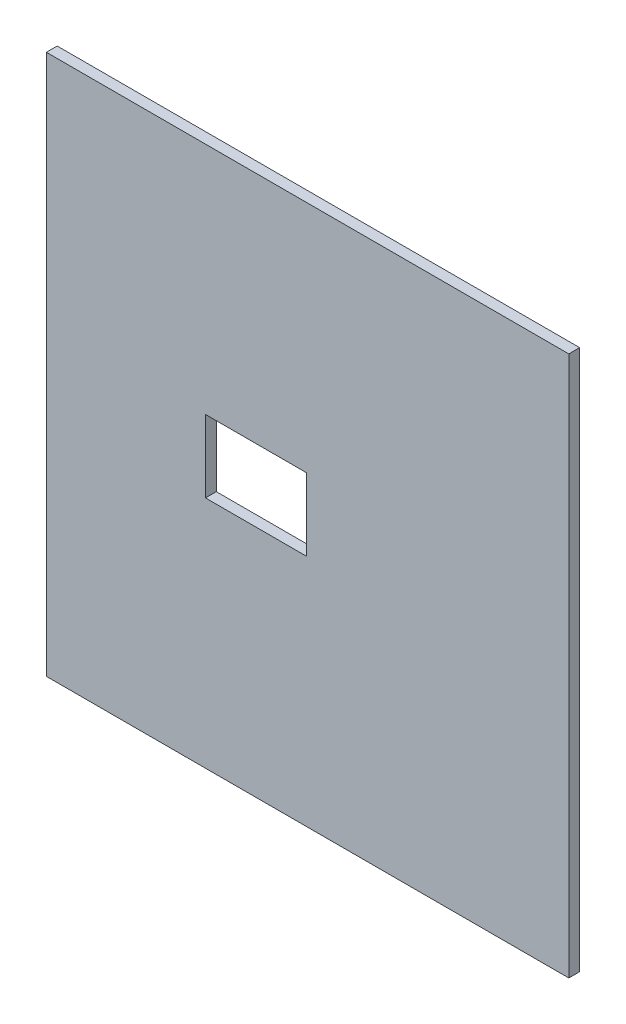
from build123d import *

# Parameters (mm, degrees)
SKETCH1_W           = 144.5
SKETCH1_H           = 149.5
BOSS_EXTRUDE1_DEPTH = 3
CUT_EXTRUDE1_REACH  = 5
SKETCH2_W           = 28
SKETCH2_H           = 20


with BuildPart() as part:
    # Sketch1 → Boss-Extrude1 (new body)
    with BuildSketch(Plane.XY):
        Rectangle(SKETCH1_W, SKETCH1_H)
    extrude(amount=BOSS_EXTRUDE1_DEPTH)

    # Sketch2 → Cut-Extrude1 (cut, up to next)
    with BuildSketch(Plane.XY.offset(3), mode=Mode.PRIVATE) as cut_extrude1_sk1:
        with Locations((-14.25, 0)):
            Rectangle(SKETCH2_W, SKETCH2_H)
    cut_extrude1_tool1 = extrude(cut_extrude1_sk1.sketch, amount=-CUT_EXTRUDE1_REACH, mode=Mode.PRIVATE) & part.part
    add(cut_extrude1_tool1.solids().sort_by_distance((-14.25, 0, 3))[0], mode=Mode.SUBTRACT)


solid = part.part
